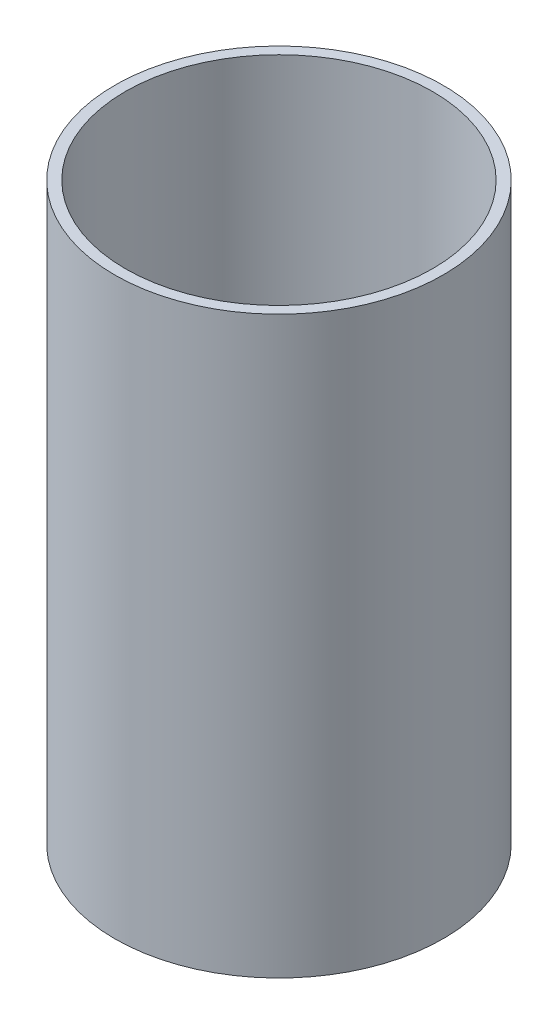
from build123d import *

# Parameters (mm, degrees)
SKETCH1_R           = 25.4
SKETCH1_R_2         = 23.749
BOSS_EXTRUDE1_DEPTH = 88.9


with BuildPart() as part:
    # Sketch1 → Boss-Extrude1 (new body)
    with BuildSketch(Plane(origin=(0, 0, 0), x_dir=(1, 0, 0), z_dir=(0, 1, 0))):
        Circle(SKETCH1_R)
        Circle(SKETCH1_R_2, mode=Mode.SUBTRACT)
    extrude(amount=BOSS_EXTRUDE1_DEPTH)


solid = part.part
